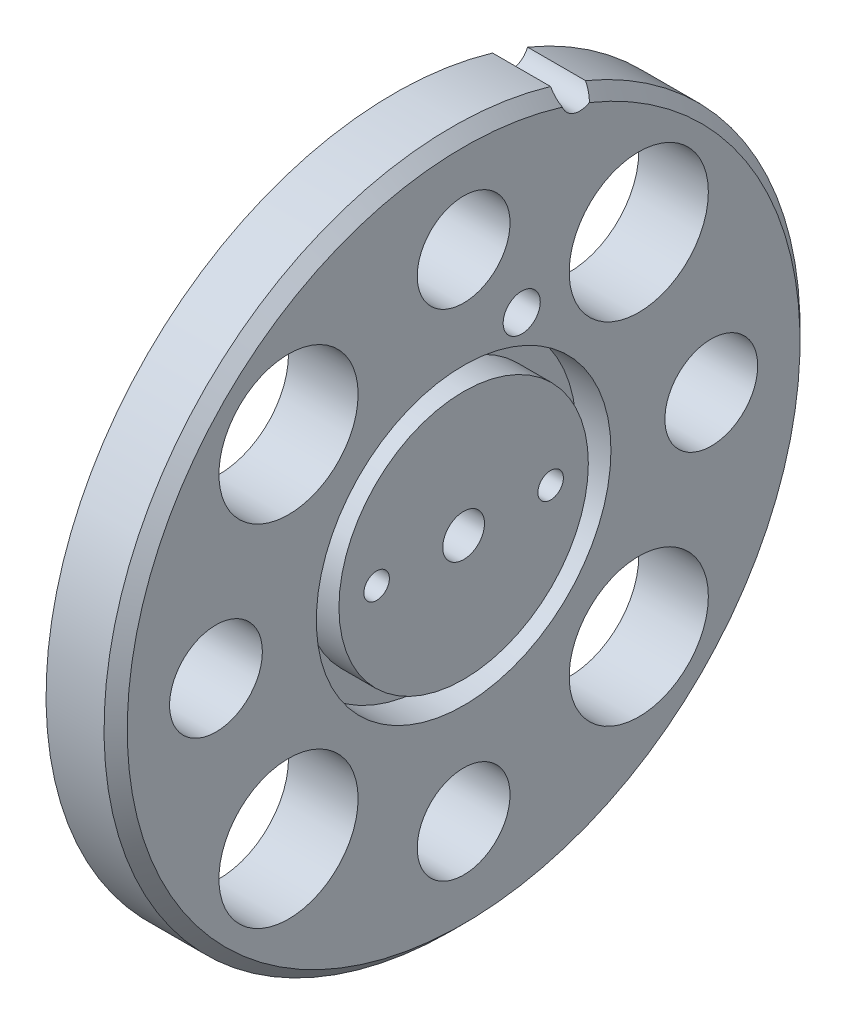
from build123d import *

# Parameters (mm, degrees)
ESQUISSE1_R             = 1.8
ESQUISSE1_R_2           = 1.1
ESQUISSE1_R_3           = 6
ESQUISSE1_R_4           = 4
BOSS_EXTRU_1_DEPTH      = 6
ESQUISSE2_R             = 12.7
ESQUISSE2_R_2           = 10.75
ESQUISSE2_R_3           = 1.6
ENL_V_MAT_EXTRU_1_DEPTH = 3
CHANFREIN1_SIZE         = 1


with BuildPart() as part:
    # Esquisse1 → Boss.-Extru.1 (new body)
    with BuildSketch(Plane(origin=(0, 0, 0), x_dir=(0, 0, -1), z_dir=(1, 0, 0))):
        with BuildLine():
            ThreePointArc((8.492273319, 28.772926404), (-10.014205777, -28.279244733), (11.507653383, 27.70512432))
            ThreePointArc((11.507653383, 27.70512432), (9.480114802, 26.771018347), (8.492273319, 28.772926404))
        make_face()
        Circle(ESQUISSE1_R, mode=Mode.SUBTRACT)
        with Locations((7.5, 0)):
            Circle(ESQUISSE1_R_2, mode=Mode.SUBTRACT)
        with Locations(Location((-7.5, 0, 0), (0, 0, 180))):  # turned: the seam where the file's is
            Circle(ESQUISSE1_R_2, mode=Mode.SUBTRACT)
        with Locations((15.096729778, -15.096729778)):
            Circle(ESQUISSE1_R_3, mode=Mode.SUBTRACT)
        with Locations((21.35, 0)):
            Circle(ESQUISSE1_R_4, mode=Mode.SUBTRACT)
        with Locations((15.096729778, 15.096729778)):
            Circle(ESQUISSE1_R_3, mode=Mode.SUBTRACT)
        with Locations((0, 21.35)):
            Circle(ESQUISSE1_R_4, mode=Mode.SUBTRACT)
        with Locations((-15.096729778, -15.096729778)):
            Circle(ESQUISSE1_R_3, mode=Mode.SUBTRACT)
        with Locations((0, -21.35)):
            Circle(ESQUISSE1_R_4, mode=Mode.SUBTRACT)
        with Locations((-15.096729778, 15.096729778)):
            Circle(ESQUISSE1_R_3, mode=Mode.SUBTRACT)
        with Locations((-21.35, 0)):
            Circle(ESQUISSE1_R_4, mode=Mode.SUBTRACT)
    extrude(amount=BOSS_EXTRU_1_DEPTH)

    # Esquisse2 → Enlèv. mat.-Extru.1 (cut)
    with BuildSketch(Plane(origin=(6, 0, 0), x_dir=(0, 0, -1), z_dir=(1, 0, 0))):
        Circle(ESQUISSE2_R)
        Circle(ESQUISSE2_R_2, mode=Mode.SUBTRACT)
        with Locations((5.007102889, 14.139622366)):
            Circle(ESQUISSE2_R_3)
    extrude(amount=-ENL_V_MAT_EXTRU_1_DEPTH, mode=Mode.SUBTRACT)

    # Chanfrein1
    chanfrein1_edges = [part.edges().sort_by_distance(p)[0] for p in [
        (6, -28.279244733, 10.014205777),
    ]]
    chamfer(chanfrein1_edges, length=CHANFREIN1_SIZE)


solid = part.part
